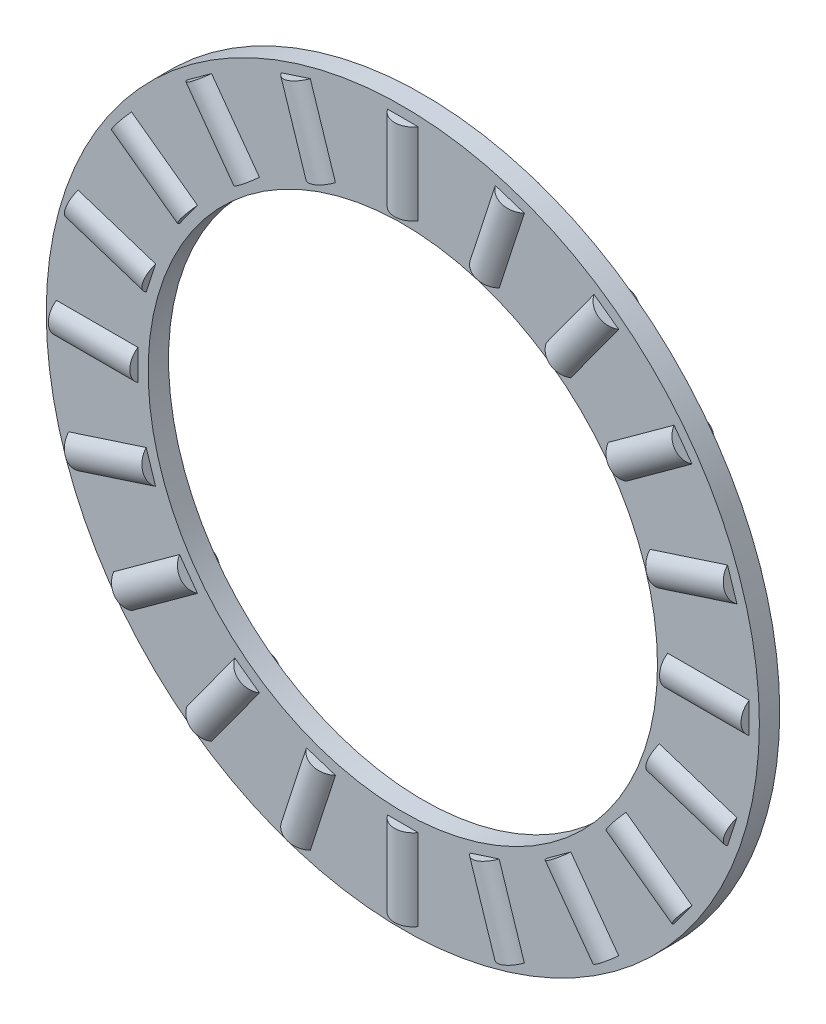
from build123d import *

# Parameters (mm, degrees)
ESQUISSE1_R                  = 35
ESQUISSE1_R_2                = 25
BOSS_EXTRU_1_DEPTH           = 2
BOSS_EXTRU_2_START           = 26
ESQUISSE2_R                  = 1.8
BOSS_EXTRU_2_DEPTH           = 8
R_P_TITION_CIRCULAIRE1_COUNT = 20


with BuildPart() as part:
    # Esquisse1 → Boss.-Extru.1 (new body)
    with BuildSketch(Plane.XY):
        Circle(ESQUISSE1_R)
        Circle(ESQUISSE1_R_2, mode=Mode.SUBTRACT)
    extrude(amount=BOSS_EXTRU_1_DEPTH)

    # Esquisse2 → Boss.-Extru.2 (add)
    with BuildSketch(Plane(origin=(0, 0, 0), x_dir=(1, 0, 0), z_dir=(0, 1, 0)).offset(BOSS_EXTRU_2_START)):
        with Locations((0, -1)):
            Circle(ESQUISSE2_R)
    boss_extru_2 = extrude(amount=BOSS_EXTRU_2_DEPTH)

    # Répétition circulaire1: Boss.-Extru.2 ×20 about axis
    r_p_tition_circulaire1_axis = Axis((0, 0, 0), (0, 0, 1))
    for i in range(1, R_P_TITION_CIRCULAIRE1_COUNT):
        add(boss_extru_2.rotate(r_p_tition_circulaire1_axis, i * 360 / R_P_TITION_CIRCULAIRE1_COUNT))


solid = part.part
